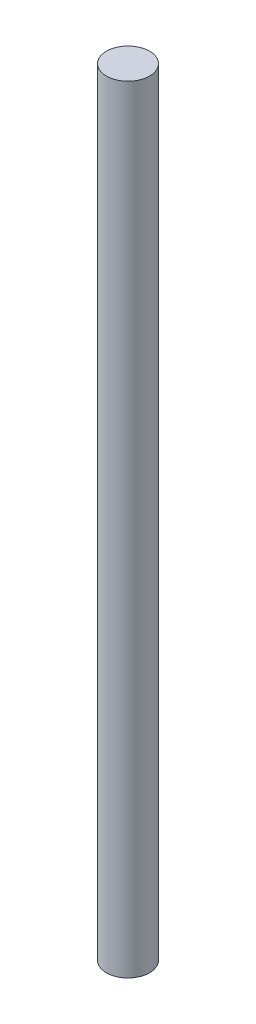
from build123d import *

# Parameters (mm, degrees)
SKETCH1_R           = 3.175
BOSS_EXTRUDE1_DEPTH = 114.3


with BuildPart() as part:
    # Sketch1 → Boss-Extrude1 (new body)
    with BuildSketch(Plane(origin=(0, 0, 0), x_dir=(1, 0, 0), z_dir=(0, 1, 0))):
        Circle(SKETCH1_R)
    extrude(amount=BOSS_EXTRUDE1_DEPTH)


solid = part.part
